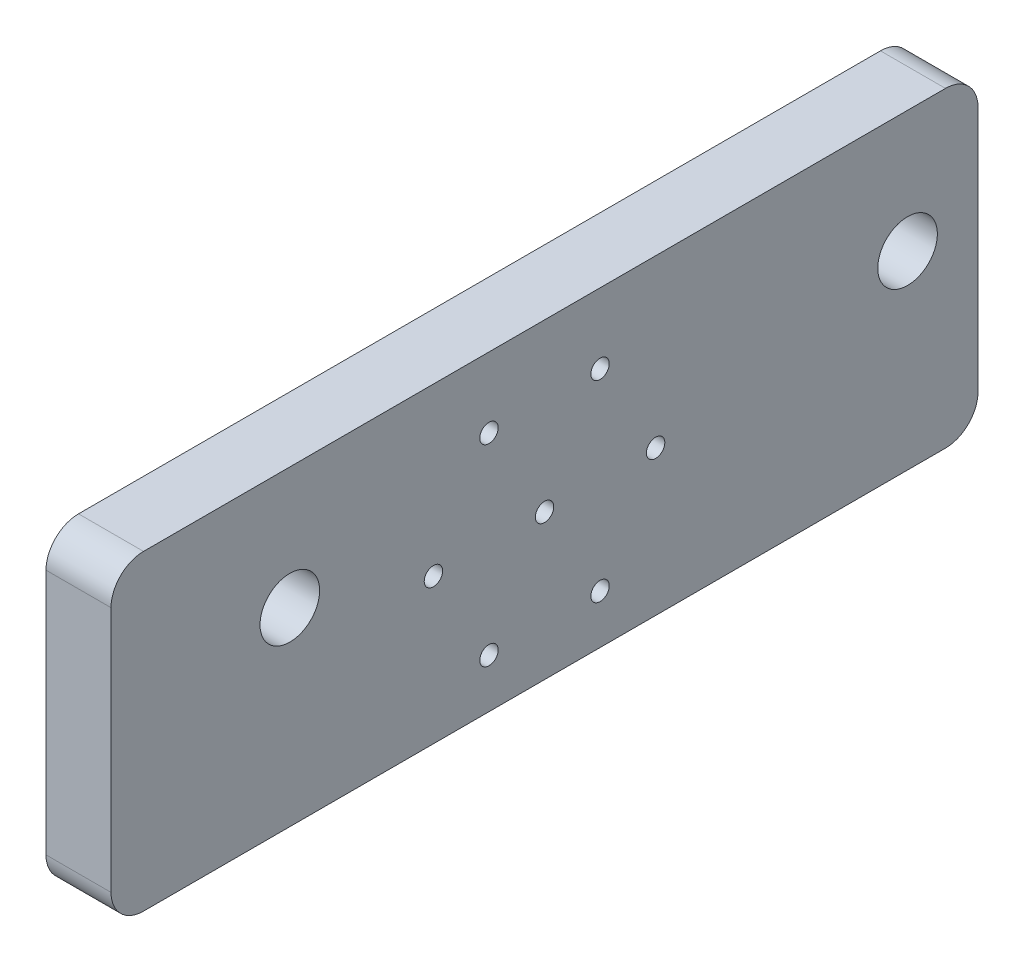
from build123d import *

# Parameters (mm, degrees)
SKETCH1_W              = 80
SKETCH1_H              = 28.75
BOSS_EXTRUDE1_DEPTH    = 6
M5_CLEARANCE_HOLE1_D   = 5.5
M1_6_CLEARANCE_HOLE1_D = 1.7
CUT_EXTRUDE1_START     = -6
SKETCH9_W              = 29.5
SKETCH9_H              = 23.753520778
CUT_EXTRUDE1_DEPTH     = 2
FILLET1_R              = 2
FILLET2_R              = 3


with BuildPart() as part:
    # Sketch1 → Boss-Extrude1 (new body)
    with BuildSketch(Plane(origin=(0, 0, 0), x_dir=(0, 0, -1), z_dir=(1, 0, 0))):
        Rectangle(SKETCH1_W, SKETCH1_H)
    extrude(amount=BOSS_EXTRUDE1_DEPTH)

    # M5 Clearance Hole1 (through all)
    with Locations(Plane.ZY):
        with Locations((-33.5, 3.125), (23.5, 3.125)):
            Hole(M5_CLEARANCE_HOLE1_D / 2)

    # M1.6 Clearance Hole1 (through all)
    with Locations(Plane.ZY):
        with Locations((-10.25, -0.975), (10.25, -0.975), (0, -0.975), (-5.125, -9.851760389), (5.125, -9.851760389), (5.125, 7.901760389), (-5.125, 7.901760389)):
            Hole(M1_6_CLEARANCE_HOLE1_D / 2)

    # Sketch9 → Cut-Extrude1 (cut)
    with BuildSketch(Plane(origin=(6, 0, 0), x_dir=(0, 0, -1), z_dir=(1, 0, 0)).offset(CUT_EXTRUDE1_START)):
        with Locations((0, -0.975)):
            Rectangle(SKETCH9_W, SKETCH9_H)
    extrude(amount=CUT_EXTRUDE1_DEPTH, mode=Mode.SUBTRACT)

    # Fillet1
    fillet1_edges = [part.edges().sort_by_distance(p)[0] for p in [
        (1, -12.851760389, 14.75),
        (1, -12.851760389, -14.75),
        (1, 10.901760389, -14.75),
        (1, 10.901760389, 14.75),
    ]]
    fillet(fillet1_edges, radius=FILLET1_R)

    # Fillet2
    fillet2_edges = [part.edges().sort_by_distance(p)[0] for p in [
        (3, -14.375, -40),
        (3, -14.375, 40),
        (3, 14.375, 40),
        (3, 14.375, -40),
    ]]
    fillet(fillet2_edges, radius=FILLET2_R)


solid = part.part
